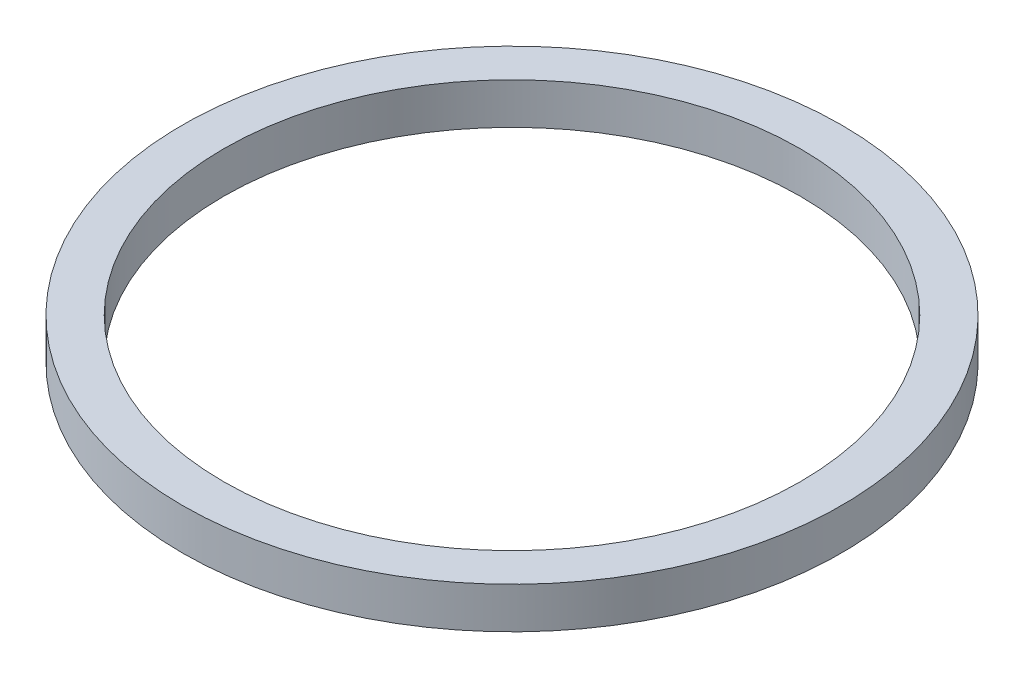
from build123d import *

# Parameters (mm, degrees)
SKETCH1_R           = 40
SKETCH1_R_2         = 35
BOSS_EXTRUDE1_DEPTH = 5


with BuildPart() as part:
    # Sketch1 → Boss-Extrude1 (new body)
    with BuildSketch(Plane(origin=(0, 0, 0), x_dir=(1, 0, 0), z_dir=(0, 1, 0))):
        Circle(SKETCH1_R)
        Circle(SKETCH1_R_2, mode=Mode.SUBTRACT)
    extrude(amount=BOSS_EXTRUDE1_DEPTH)


solid = part.part
